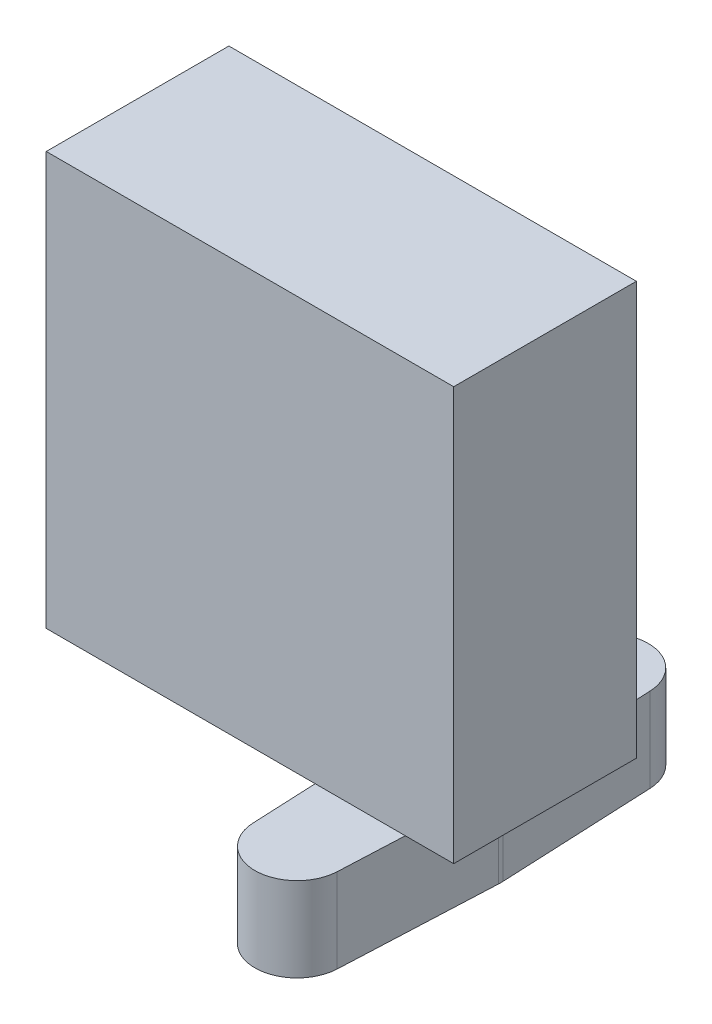
from build123d import *

# Parameters (mm, degrees)
SKETCH1_W           = 29
SKETCH1_H           = 29.4
BOSS_EXTRUDE1_DEPTH = 6.5
BOSS_EXTRUDE2_DEPTH = 6


with BuildPart() as part:
    # Sketch1 → Boss-Extrude1 (new, symmetric)
    with BuildSketch(Plane.XY):
        Rectangle(SKETCH1_W, SKETCH1_H)
    extrude(amount=BOSS_EXTRUDE1_DEPTH, both=True)


with BuildPart() as body_2:
    # Sketch3 → Boss-Extrude2 (new body)
    with BuildSketch(Plane.XZ.offset(14.7)):
        with BuildLine():
            Line((4.353617572, -0.159090909), (4.853100776, -11.136363636))
            ThreePointArc((4.853100776, -11.136363636), (7.85, -14), (10.846899224, -11.136363636))
            Line((10.846899224, -11.136363636), (11.346382428, -0.159090909))
            ThreePointArc((11.346382428, -0.159090909), (11.35, 0), (11.346382428, 0.159090909))
            Line((11.346382428, 0.159090909), (10.846899224, 11.136363636))
            ThreePointArc((10.846899224, 11.136363636), (7.85, 14), (4.853100776, 11.136363636))
            Line((4.853100776, 11.136363636), (4.353617572, 0.159090909))
            ThreePointArc((4.353617572, 0.159090909), (4.35, 0), (4.353617572, -0.159090909))
        make_face()
    extrude(amount=BOSS_EXTRUDE2_DEPTH)


solid = Compound([part.part, body_2.part])
